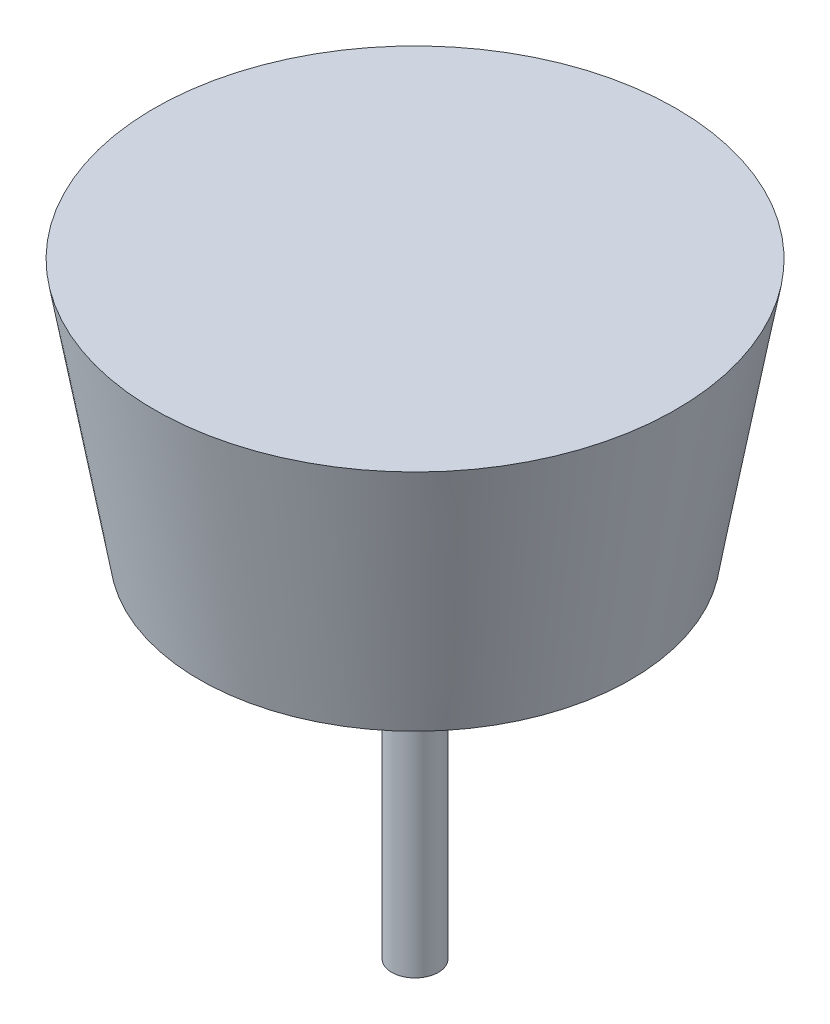
from build123d import *

# Parameters (mm, degrees)
SKETCH1_W = 1
SKETCH1_H = 25


with BuildPart() as part:
    # Sketch1 → Revolve1 (revolve)
    with BuildSketch(Plane.XY):
        with Locations((0.5, 12.5)):
            Rectangle(SKETCH1_W, SKETCH1_H)
    revolve(axis=Axis((0, 0, 0), (0, 1, 0)))

    # Sketch2 → Revolve2 (revolve)
    with BuildSketch(Plane.XY):
        Polygon((0, 25), (10, 25), (8.267349052, 15.173648178), (9.252156805, 15), (11.191753593, 26), (0, 26), align=None)
    revolve(axis=Axis((0, 0, 0), (0, 1, 0)))


solid = part.part
